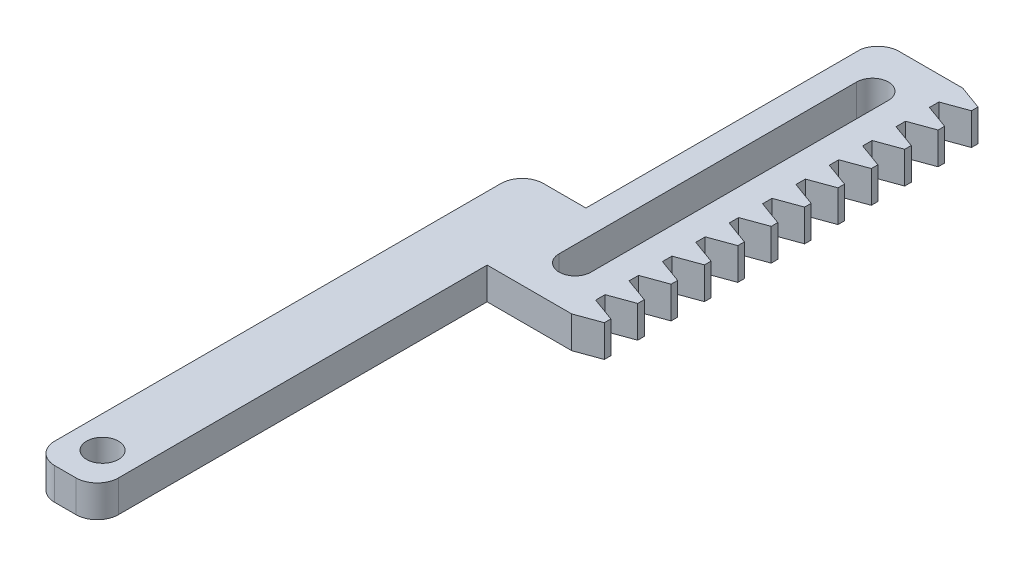
from build123d import *

# Parameters (mm, degrees)
CROQUIS1_R              = 1.5
SALIENTE_EXTRUIR2_DEPTH = 3


with BuildPart() as part:
    # Croquis1 → Saliente-Extruir2 (new body)
    with BuildSketch(Plane(origin=(0, 0, 0), x_dir=(1, 0, 0), z_dir=(0, 1, 0))):
        with BuildLine():
            Line((0.222991841, 27.097579335), (6.222991841, 27.097579335))
            Line((6.222991841, 27.097579335), (8.472991841, 26.278646308))
            Line((8.472991841, 26.278646308), (8.472991841, 25.663790451))
            Line((8.472991841, 25.663790451), (6.222991841, 24.844857424))
            Line((6.222991841, 24.844857424), (6.222991841, 23.955986685))
            Line((6.222991841, 23.955986685), (8.472991841, 23.137053658))
            Line((8.472991841, 23.137053658), (8.472991841, 22.522197801))
            Line((8.472991841, 22.522197801), (6.222991841, 21.703264774))
            Line((6.222991841, 21.703264774), (6.222991841, 20.814394035))
            Line((6.222991841, 20.814394035), (8.472991841, 19.995461008))
            Line((8.472991841, 19.995461008), (8.472991841, 19.380605151))
            Line((8.472991841, 19.380605151), (6.222991841, 18.561672124))
            Line((6.222991841, 18.561672124), (6.222991841, 17.672801385))
            Line((6.222991841, 17.672801385), (8.472991841, 16.853868358))
            Line((8.472991841, 16.853868358), (8.472991841, 16.239012501))
            Line((8.472991841, 16.239012501), (6.222991841, 15.420079474))
            Line((6.222991841, 15.420079474), (6.222991841, 14.531208735))
            Line((6.222991841, 14.531208735), (8.472991841, 13.712275708))
            Line((8.472991841, 13.712275708), (8.472991841, 13.097419851))
            Line((8.472991841, 13.097419851), (6.222991841, 12.278486824))
            Line((6.222991841, 12.278486824), (6.222991841, 11.389616085))
            Line((6.222991841, 11.389616085), (8.472991841, 10.570683058))
            Line((8.472991841, 10.570683058), (8.472991841, 9.955827201))
            Line((8.472991841, 9.955827201), (6.222991841, 9.136894174))
            Line((6.222991841, 9.136894174), (6.222991841, 8.248023435))
            Line((6.222991841, 8.248023435), (8.472991841, 7.429090408))
            Line((8.472991841, 7.429090408), (8.472991841, 6.814234551))
            Line((8.472991841, 6.814234551), (6.222991841, 5.995301524))
            Line((6.222991841, 5.995301524), (6.222991841, 5.106430785))
            Line((6.222991841, 5.106430785), (8.472991841, 4.287497758))
            Line((8.472991841, 4.287497758), (8.472991841, 3.672641901))
            Line((8.472991841, 3.672641901), (6.222991841, 2.853708874))
            Line((6.222991841, 2.853708874), (6.222991841, 1.964838135))
            Line((6.222991841, 1.964838135), (8.472991841, 1.145905108))
            Line((8.472991841, 1.145905108), (8.472991841, 0.531049251))
            Line((8.472991841, 0.531049251), (6.222991841, -0.287883776))
            Line((6.222991841, -0.287883776), (6.222991841, -1.176754515))
            Line((6.222991841, -1.176754515), (8.472991841, -1.995687542))
            Line((8.472991841, -1.995687542), (8.472991841, -2.610543399))
            Line((8.472991841, -2.610543399), (6.222991841, -3.429476426))
            Line((6.222991841, -3.429476426), (6.222991841, -4.318347165))
            Line((6.222991841, -4.318347165), (8.472991841, -5.137280192))
            Line((8.472991841, -5.137280192), (8.472991841, -5.752136049))
            Line((8.472991841, -5.752136049), (6.222991841, -6.571069076))
            Line((6.222991841, -6.571069076), (6.222991841, -7.459939815))
            Line((6.222991841, -7.459939815), (8.472991841, -8.278872842))
            Line((8.472991841, -8.278872842), (8.472991841, -8.893728699))
            Line((8.472991841, -8.893728699), (6.222991841, -9.712661726))
            Line((6.222991841, -9.712661726), (0.256792505, -9.712661726))
            Line((0.256792505, -9.712661726), (-1.743207495, -9.712661726))
            Line((-1.743207495, -9.712661726), (-1.743207495, -44.412661726))
            ThreePointArc((-1.743207495, -44.412661726), (-2.328993932, -45.826875288), (-3.743207495, -46.412661726))
            Line((-3.743207495, -46.412661726), (-5.743207495, -46.412661726))
            ThreePointArc((-5.743207495, -46.412661726), (-7.157421057, -45.826875288), (-7.743207495, -44.412661726))
            Line((-7.743207495, -44.412661726), (-7.743207495, -6.412661726))
            Line((-7.743207495, -6.412661726), (-7.743207495, -4.412661726))
            Line((-7.743207495, -4.412661726), (-7.743207495, -2.412661726))
            ThreePointArc((-7.743207495, -2.412661726), (-7.157421057, -0.998448163), (-5.743207495, -0.412661726))
            Line((-5.743207495, -0.412661726), (-1.743207495, -0.412661726))
            Line((-1.743207495, -0.412661726), (-1.743207495, 25.463721618))
            ThreePointArc((-1.743207495, 25.463721618), (-1.055232598, 26.635806328), (0.222991841, 27.097579335))
        make_face()
        with Locations((-4.743207495, -42.912661726)):
            Circle(CROQUIS1_R, mode=Mode.SUBTRACT)
        with BuildLine():
            Line((3.722991841, 22.597579335), (3.722991841, -5.402420665))
            ThreePointArc((3.722991841, -5.402420665), (2.222991841, -6.902420665), (0.722991841, -5.402420665))
            Line((0.722991841, -5.402420665), (0.722991841, 22.597579335))
            ThreePointArc((0.722991841, 22.597579335), (2.222991841, 24.097579335), (3.722991841, 22.597579335))
        make_face(mode=Mode.SUBTRACT)
    extrude(amount=SALIENTE_EXTRUIR2_DEPTH)


solid = part.part
